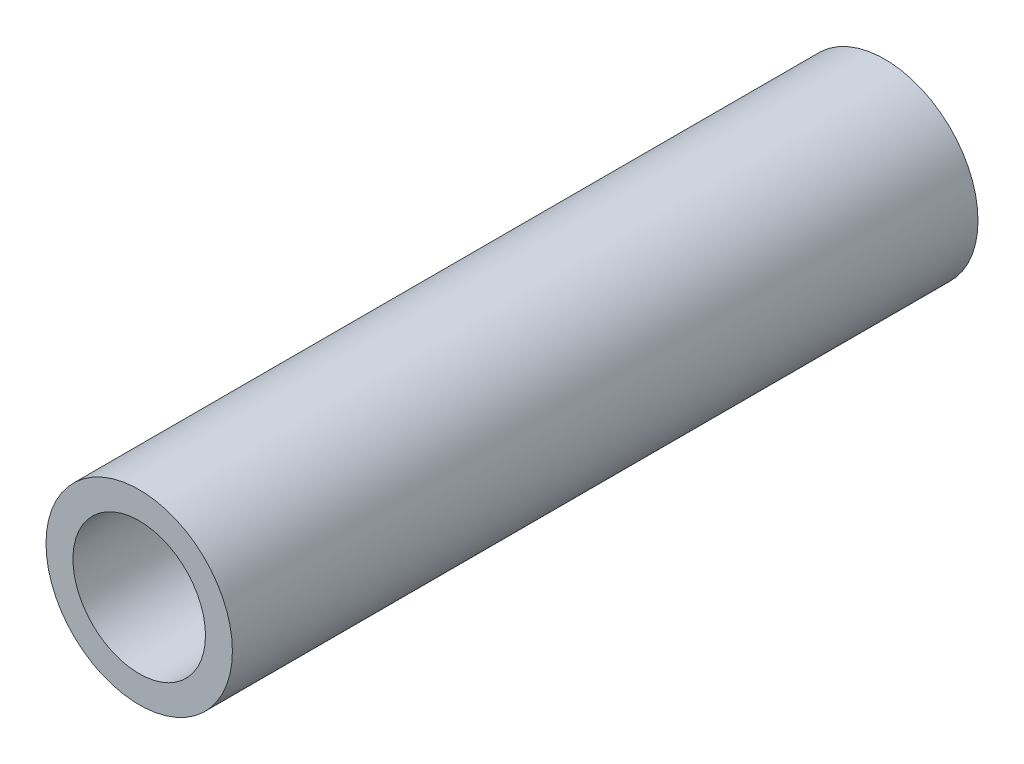
from build123d import *

# Parameters (mm, degrees)
SKETCH1_R      = 2.25
SKETCH1_R_2    = 1.6
EXTRUDE1_DEPTH = 9


with BuildPart() as part:
    # Sketch1 → Extrude1 (new body, symmetric)
    with BuildSketch(Plane.XY):
        Circle(SKETCH1_R)
        Circle(SKETCH1_R_2, mode=Mode.SUBTRACT)
    extrude(amount=EXTRUDE1_DEPTH, both=True)


solid = part.part
